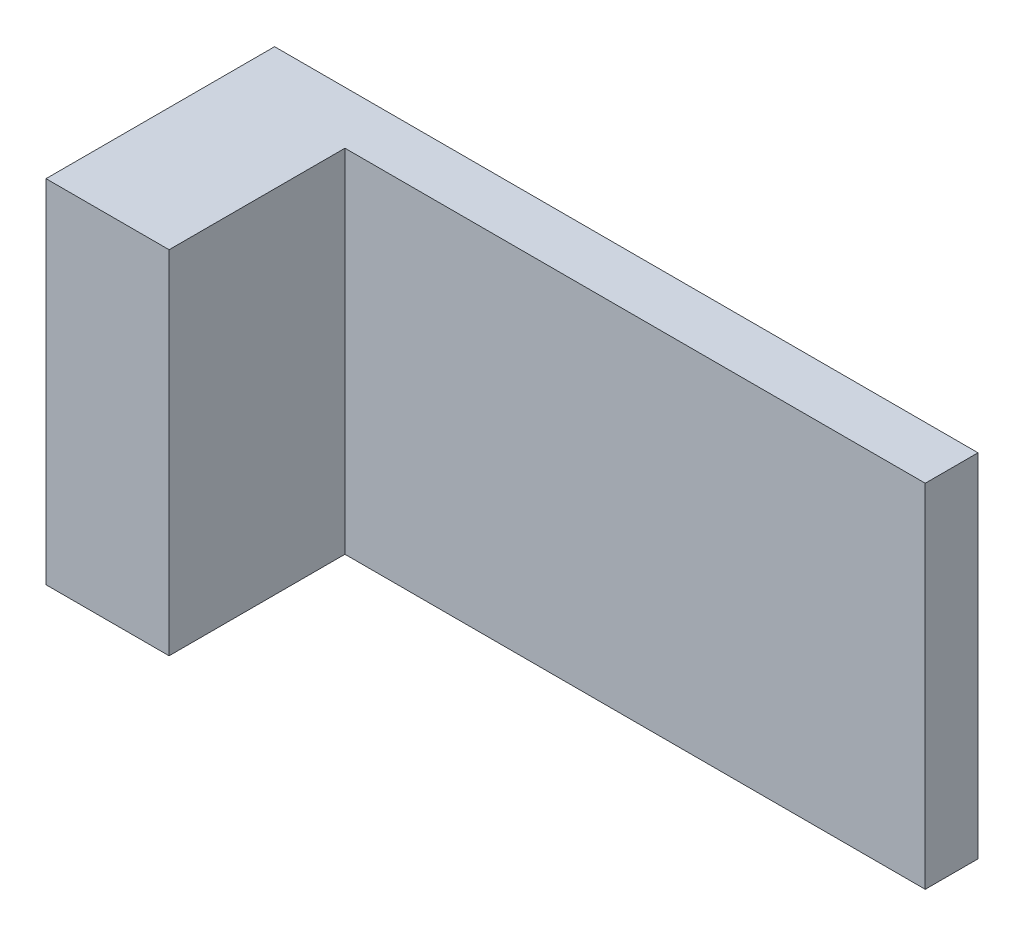
from build123d import *

# Parameters (mm, degrees)
SKETCH1_W           = 40
SKETCH1_H           = 20
BOSS_EXTRUDE1_DEPTH = 1.5
SKETCH2_W           = 7
SKETCH2_H           = 20
BOSS_EXTRUDE2_DEPTH = 10


with BuildPart() as part:
    # Sketch1 → Boss-Extrude1 (new body, symmetric)
    with BuildSketch(Plane.XY):
        Rectangle(SKETCH1_W, SKETCH1_H)
    extrude(amount=BOSS_EXTRUDE1_DEPTH, both=True)

    # Sketch2 → Boss-Extrude2 (add)
    with BuildSketch(Plane.XY.offset(1.5)):
        with Locations((-16.5, 0)):
            Rectangle(SKETCH2_W, SKETCH2_H)
    extrude(amount=BOSS_EXTRUDE2_DEPTH)


solid = part.part
